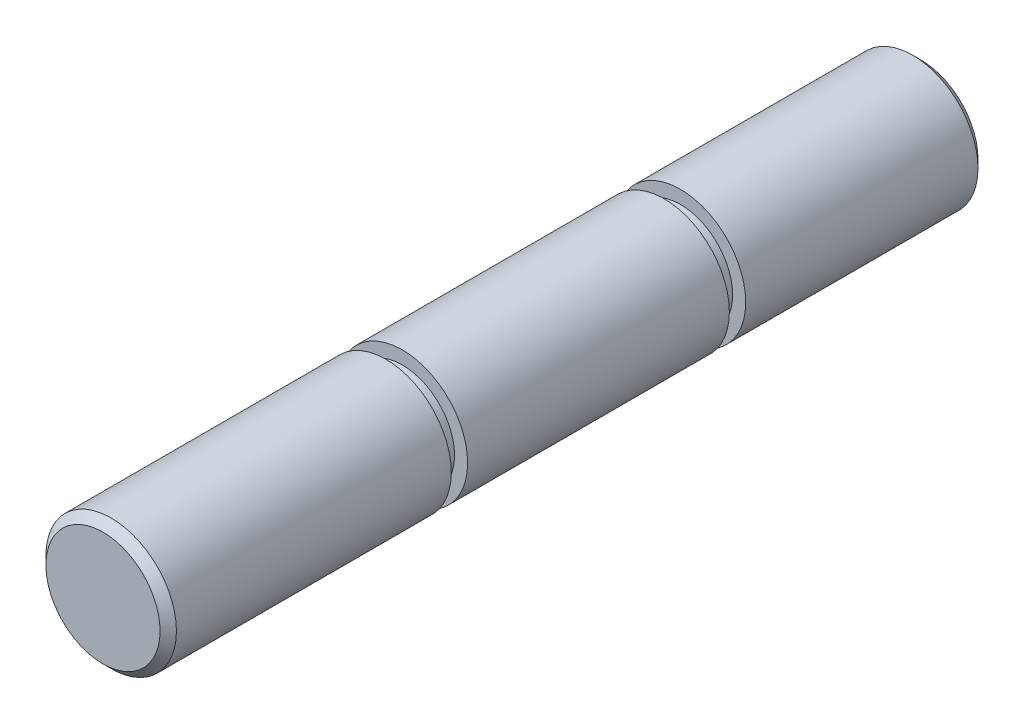
from build123d import *

# Parameters (mm, degrees)
CROQUIS1_R              = 3.99
SALIENTE_EXTRUIR1_DEPTH = 50
CROQUIS2_W              = 1
CROQUIS2_H              = 0.8
CHAFL_N1_SIZE           = 0.5


with BuildPart() as part:
    # Croquis1 → Saliente-Extruir1 (new body)
    with BuildSketch(Plane.XY):
        Circle(CROQUIS1_R)
    extrude(amount=SALIENTE_EXTRUIR1_DEPTH)

    # Croquis2 → Cortar-Revolución1 (revolve, cut)
    with BuildSketch(Plane(origin=(0, 0, 0), x_dir=(0, 0, -1), z_dir=(1, 0, 0))):
        with Locations((-15.2, 3.59)):
            Rectangle(CROQUIS2_W, CROQUIS2_H)
        with Locations((-32.2, 3.59)):
            Rectangle(CROQUIS2_W, CROQUIS2_H)
    revolve(axis=Axis((0, 0, 50), (0, 0, -1)), mode=Mode.SUBTRACT)

    # Chaflán1
    chafl_n1_edges = [part.edges().sort_by_distance(p)[0] for p in [
        (-3.99, 0, 0),
        (-3.99, 0, 50),
    ]]
    chamfer(chafl_n1_edges, length=CHAFL_N1_SIZE)


solid = part.part
